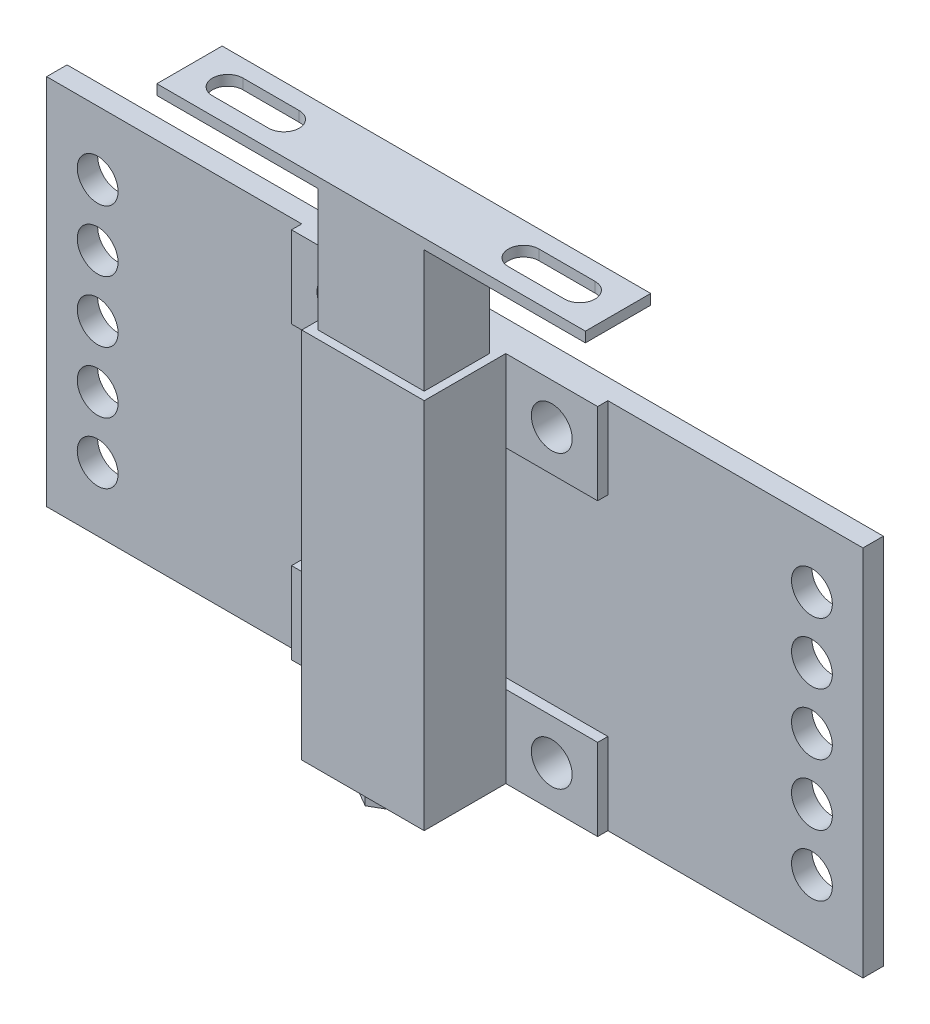
from build123d import *

# Parameters (mm, degrees)
SKETCH2_W           = 95.25
SKETCH2_H           = 25.4
SKETCH2_R           = 6.35
EXTRUDE1_DEPTH      = 3.175
EXTRUDE1_2_DEPTH    = 3.175
SKETCH3_W           = 38.1
SKETCH3_H           = 115.8875
EXTRUDE2_DEPTH      = 25.4
SKETCH4_W           = 33.02
SKETCH4_H           = 20.32
EXTRUDE3_DEPTH      = 38.1
SKETCH5_W           = 133.35
SKETCH5_H           = 20.32
EXTRUDE4_DEPTH      = 3.175
CUT_EXTRUDE1_DEPTH  = 158.1625
EXTRUDE5_DEPTH      = 3.175
SKETCH9_R           = 6.35
EXTRUDE6_DEPTH      = 3.175
SKETCH10_W          = 254
SKETCH10_H          = 115.8875
EXTRUDE7_DEPTH      = 6.35
SKETCH11_R          = 6.35
CUT_EXTRUDE2_DEPTH  = 7.35
SKETCH12_R          = 6.35
CUT_EXTRUDE3_DEPTH  = 35.925
LPATTERN1_COUNT     = 3
LPATTERN1_PITCH     = 19.05
LPATTERN1_COL_COUNT = 3
LPATTERN1_COL_PITCH = 19.05


with BuildPart() as part:
    # Sketch2 → Extrude1 (new body)
    with BuildSketch(Plane.XY):
        with Locations((0, -45.24375)):
            Rectangle(SKETCH2_W, SKETCH2_H)
        with Locations((-33.3375, -45.24375)):
            Circle(SKETCH2_R, mode=Mode.SUBTRACT)
        with Locations((33.3375, -45.24375)):
            Circle(SKETCH2_R, mode=Mode.SUBTRACT)
    extrude(amount=EXTRUDE1_DEPTH)



with BuildPart() as body_2:
    # Sketch2 → Extrude1 2 (new body)
    with BuildSketch(Plane.XY):
        with Locations((0, 45.24375)):
            Rectangle(SKETCH2_W, SKETCH2_H)
        with Locations((33.3375, 45.24375)):
            Circle(SKETCH2_R, mode=Mode.SUBTRACT)
        with Locations((-33.3375, 45.24375)):
            Circle(SKETCH2_R, mode=Mode.SUBTRACT)
    extrude(amount=EXTRUDE1_2_DEPTH)


with BuildPart() as part_1:
    add(part.part)

    add(body_2.part)  # Extrude2 merges body 2
    # Sketch3 → Extrude2 (add)
    with BuildSketch(Plane.XY.offset(3.175)):
        Rectangle(SKETCH3_W, SKETCH3_H)
    extrude(amount=EXTRUDE2_DEPTH)

    # Sketch4 → Extrude3 (add)
    with BuildSketch(Plane(origin=(0, 57.94375, 0), x_dir=(1, 0, 0), z_dir=(0, 1, 0))):
        with Locations((0, -15.875)):
            Rectangle(SKETCH4_W, SKETCH4_H)
    extrude(amount=EXTRUDE3_DEPTH)

    # Sketch5 → Extrude4 (add)
    with BuildSketch(Plane(origin=(0, 96.04375, 0), x_dir=(1, 0, 0), z_dir=(0, 1, 0))):
        with Locations((0, -15.875)):
            Rectangle(SKETCH5_W, SKETCH5_H)
    extrude(amount=EXTRUDE4_DEPTH)

    # Sketch6 → Cut-Extrude1 (cut, through all)
    with BuildSketch(Plane(origin=(0, 99.21875, 0), x_dir=(1, 0, 0), z_dir=(0, 1, 0))):
        with BuildLine():
            Line((54.76875, -20.6375), (37.30625, -20.6375))
            ThreePointArc((37.30625, -20.6375), (32.54375, -15.875), (37.30625, -11.1125))
            Line((37.30625, -11.1125), (54.76875, -11.1125))
            ThreePointArc((54.76875, -11.1125), (59.53125, -15.875), (54.76875, -20.6375))
        make_face()
        with BuildLine():
            Line((-54.76875, -11.1125), (-37.30625, -11.1125))
            ThreePointArc((-37.30625, -11.1125), (-32.54375, -15.875), (-37.30625, -20.6375))
            Line((-37.30625, -20.6375), (-54.76875, -20.6375))
            ThreePointArc((-54.76875, -20.6375), (-59.53125, -15.875), (-54.76875, -11.1125))
        make_face()
    extrude(amount=-CUT_EXTRUDE1_DEPTH, mode=Mode.SUBTRACT)

    # Sketch8 → Extrude5 (add)
    with BuildSketch(Plane.XZ.offset(57.94375)):
        Polygon((12.065, 6.965730998), (12.065, 20.897192993), (0, 27.862923991), (-12.065, 20.897192993), (-12.065, 6.965730998), (0, 0), align=None)
    extrude(amount=EXTRUDE5_DEPTH)

    # Sketch9 → Extrude6 (add)
    with BuildSketch(Plane.XZ.offset(61.11875)):
        with Locations((0, 13.931461996)):
            Circle(SKETCH9_R)
    extrude(amount=EXTRUDE6_DEPTH)

    # Sketch10 → Extrude7 (add)
    with BuildSketch(Plane(origin=(0, 0, 0), x_dir=(-1, 0, 0), z_dir=(0, 0, -1))):
        Rectangle(SKETCH10_W, SKETCH10_H)
    extrude(amount=EXTRUDE7_DEPTH)

    # Sketch11 → Cut-Extrude2 (cut, through all)
    with BuildSketch(Plane.XY):
        with Locations((33.3375, -45.24375)):
            Circle(SKETCH11_R)
        with Locations((-33.3375, -45.24375)):
            Circle(SKETCH11_R)
        with Locations((-33.3375, 45.24375)):
            Circle(SKETCH11_R)
        with Locations((33.3375, 45.24375)):
            Circle(SKETCH11_R)
    extrude(amount=-CUT_EXTRUDE2_DEPTH, mode=Mode.SUBTRACT)

    # Sketch12 → Cut-Extrude3 (cut, through all)
    with BuildSketch(Plane(origin=(0, 0, -6.35), x_dir=(-1, 0, 0), z_dir=(0, 0, -1))):
        with Locations((-111.125, 0)):
            Circle(SKETCH12_R)
        with Locations((111.125, 0)):
            Circle(SKETCH12_R)
    cut_extrude3 = extrude(amount=-CUT_EXTRUDE3_DEPTH, mode=Mode.SUBTRACT)

    # LPattern1: Cut-Extrude3 ×3
    with Locations(*[(0, i * LPATTERN1_PITCH, 0) for i in range(1, LPATTERN1_COUNT)]):
        add(cut_extrude3, mode=Mode.SUBTRACT)

    # LPattern1 col: Cut-Extrude3 ×3
    with Locations(*[(0, -i * LPATTERN1_COL_PITCH, 0) for i in range(1, LPATTERN1_COL_COUNT)]):
        add(cut_extrude3, mode=Mode.SUBTRACT)


solid = part_1.part
